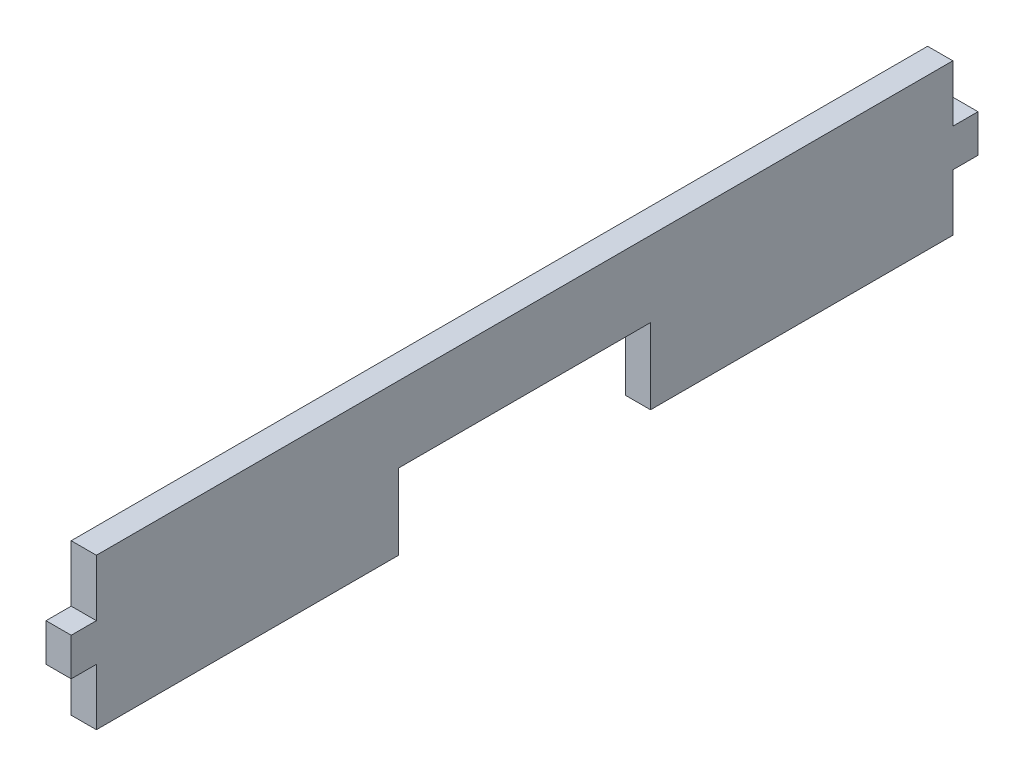
from build123d import *

# Parameters (mm, degrees)
BOSS_EXTRUDE1_DEPTH = 2.54
CUT_EXTRUDE1_REACH  = 4.54
SKETCH2_W           = 25.4
SKETCH2_H           = 7.62


with BuildPart() as part:
    # Sketch1 → Boss-Extrude1 (new body)
    with BuildSketch(Plane(origin=(0, 0, 0), x_dir=(0, 0, -1), z_dir=(1, 0, 0))):
        Polygon((-43.18, 7.62), (-43.18, 1.905), (-45.72, 1.905), (-45.72, -1.905), (-43.18, -1.905), (-43.18, -7.62), (43.18, -7.62), (43.18, -1.905), (45.72, -1.905), (45.72, 1.905), (43.18, 1.905), (43.18, 7.62), align=None)
    extrude(amount=BOSS_EXTRUDE1_DEPTH)

    # Sketch2 → Cut-Extrude1 (cut, up to next)
    with BuildSketch(Plane(origin=(2.54, 0, 0), x_dir=(0, 0, -1), z_dir=(1, 0, 0)), mode=Mode.PRIVATE) as cut_extrude1_sk1:
        with Locations((0, -3.81)):
            Rectangle(SKETCH2_W, SKETCH2_H)
    cut_extrude1_tool1 = extrude(cut_extrude1_sk1.sketch, amount=-CUT_EXTRUDE1_REACH, mode=Mode.PRIVATE) & part.part
    add(cut_extrude1_tool1.solids().sort_by_distance((2.54, -3.81, 0))[0], mode=Mode.SUBTRACT)


solid = part.part
